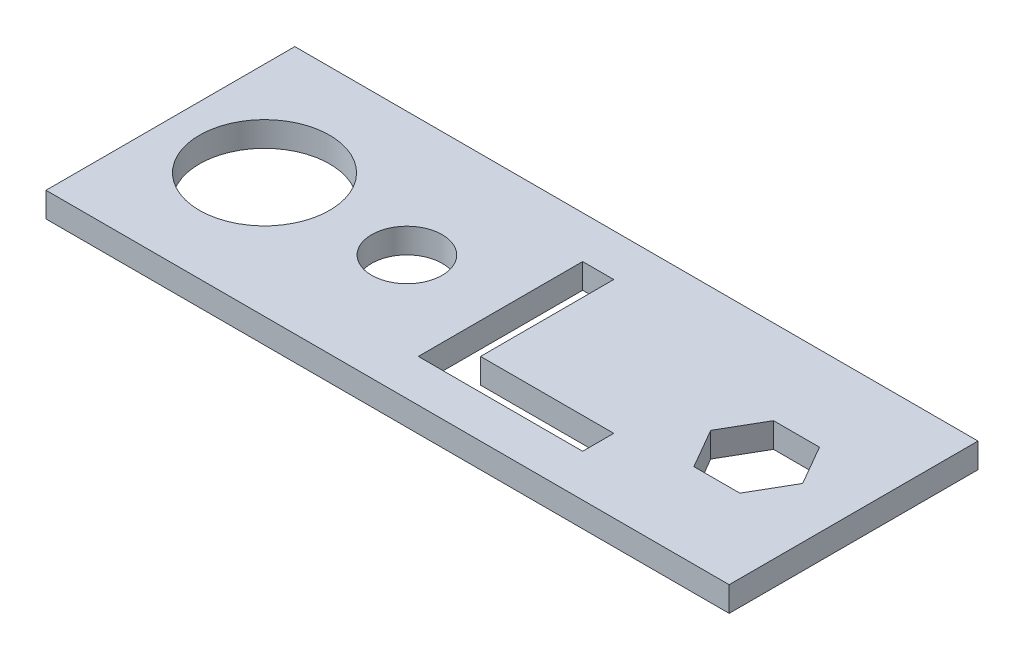
from build123d import *

# Parameters (mm, degrees)
SKETCH1_W           = 82.363290913
SKETCH1_H           = 30
SKETCH1_R           = 7.85
SKETCH1_R_2         = 4.25
BOSS_EXTRUDE1_DEPTH = 3


with BuildPart() as part:
    # Sketch1 → Boss-Extrude1 (new body)
    with BuildSketch(Plane(origin=(0, 0, 0), x_dir=(1, 0, 0), z_dir=(0, 1, 0))):
        with Locations((41.181645457, 15)):
            Rectangle(SKETCH1_W, SKETCH1_H)
        with Locations((11.345620056, 15)):
            Circle(SKETCH1_R, mode=Mode.SUBTRACT)
        with Locations((28.511842514, 15)):
            Circle(SKETCH1_R_2, mode=Mode.SUBTRACT)
        Polygon((39.793849498, 24.905), (39.793849498, 5.095), (59.603849498, 5.095), (59.603849498, 8.845), (43.543849498, 8.845), (43.543849498, 24.905), align=None, mode=Mode.SUBTRACT)
        Polygon((73.451698593, 19.8), (67.909136009, 19.8), (65.137854717, 15), (67.909136009, 10.2), (73.451698593, 10.2), (76.222979886, 15), align=None, mode=Mode.SUBTRACT)
    extrude(amount=BOSS_EXTRUDE1_DEPTH)


solid = part.part
